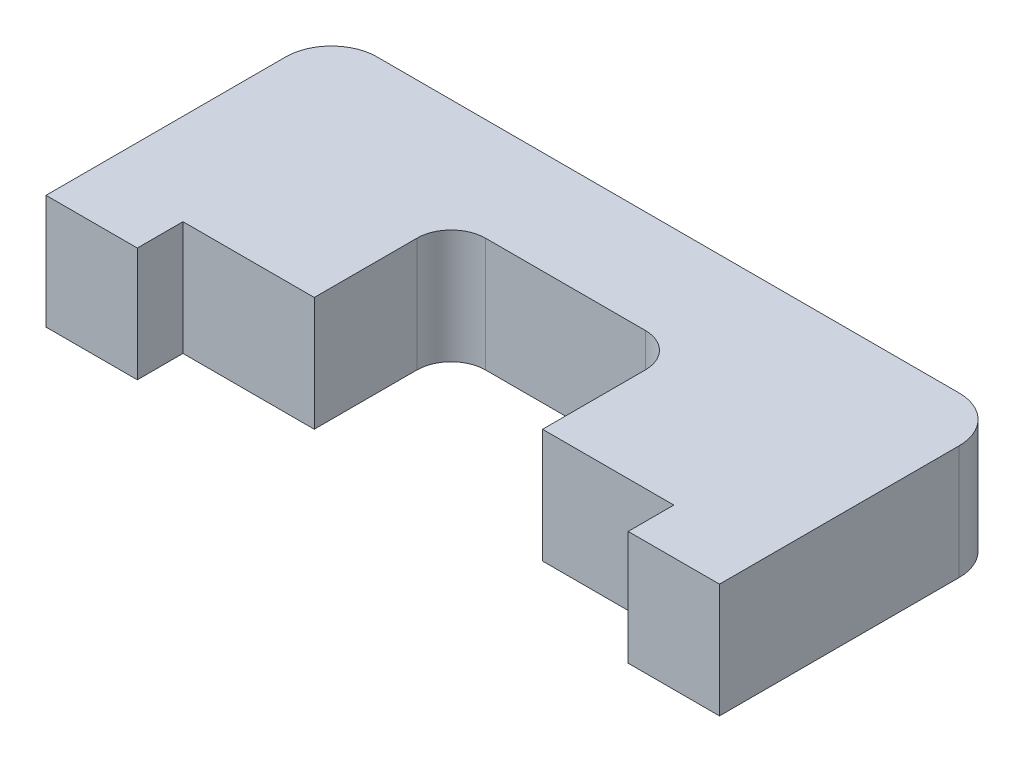
from build123d import *

# Parameters (mm, degrees)
SKETCH1_W           = 29.5
SKETCH1_H           = 12.5
BOSS_EXTRUDE1_DEPTH = 5
SKETCH2_W           = 10
SKETCH2_H           = 8
CUT_EXTRUDE1_DEPTH  = 6
FILLET1_R           = 2
FILLET2_R           = 1.5
SKETCH3_W           = 21.5
SKETCH3_H           = 5
CUT_EXTRUDE2_DEPTH  = 2


with BuildPart() as part:
    # Sketch1 → Boss-Extrude1 (new body)
    with BuildSketch(Plane(origin=(0, 0, 0), x_dir=(1, 0, 0), z_dir=(0, 1, 0))):
        Rectangle(SKETCH1_W, SKETCH1_H)
    extrude(amount=BOSS_EXTRUDE1_DEPTH)

    # Sketch2 → Cut-Extrude1 (cut, through all)
    with BuildSketch(Plane(origin=(0, 5, 0), x_dir=(1, 0, 0), z_dir=(0, 1, 0))):
        with Locations((0, -2.25)):
            Rectangle(SKETCH2_W, SKETCH2_H)
    extrude(amount=-CUT_EXTRUDE1_DEPTH, mode=Mode.SUBTRACT)

    # Fillet1
    fillet1_edges = [part.edges().sort_by_distance(p)[0] for p in [
        (-14.75, 2.5, -6.25),
        (14.75, 2.5, -6.25),
    ]]
    fillet(fillet1_edges, radius=FILLET1_R)

    # Fillet2
    fillet2_edges = [part.edges().sort_by_distance(p)[0] for p in [
        (-5, 2.5, -1.75),
        (5, 2.5, -1.75),
    ]]
    fillet(fillet2_edges, radius=FILLET2_R)

    # Sketch3 → Cut-Extrude2 (cut)
    with BuildSketch(Plane.XY.offset(6.25)):
        with Locations((0, 2.5)):
            Rectangle(SKETCH3_W, SKETCH3_H)
    extrude(amount=-CUT_EXTRUDE2_DEPTH, mode=Mode.SUBTRACT)


solid = part.part
